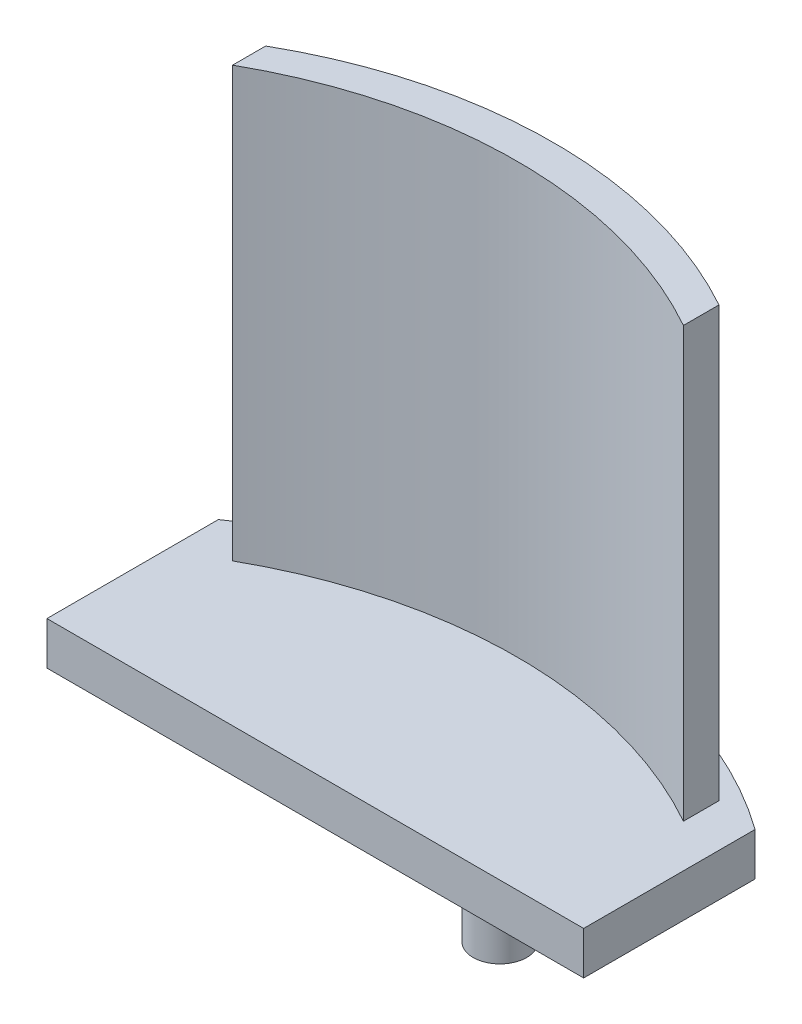
from build123d import *

# Parameters (mm, degrees)
BOSS_EXTRUDE1_DEPTH = 2.54
BOSS_EXTRUDE2_DEPTH = 25.4
SKETCH4_W           = 31.75
SKETCH4_H           = 16.51
CUT_EXTRUDE1_DEPTH  = 2.54
SKETCH5_R           = 1.5875
BOSS_EXTRUDE3_DEPTH = 12.7


with BuildPart() as part:
    # Sketch1 → Boss-Extrude1 (new body)
    with BuildSketch(Plane(origin=(0, 0, 0), x_dir=(1, 0, 0), z_dir=(0, 1, 0))):
        with BuildLine():
            Line((0, 0), (31.75, 0))
            Line((31.75, 0), (31.75, 26.649569904))
            ThreePointArc((31.75, 26.649569904), (15.875, 31.75), (0, 26.649569904))
            Line((0, 26.649569904), (0, 0))
        make_face()
    extrude(amount=BOSS_EXTRUDE1_DEPTH)

    # Sketch2 → Boss-Extrude2 (add)
    with BuildSketch(Plane(origin=(0, 2.54, 0), x_dir=(1, 0, 0), z_dir=(0, 1, 0))):
        with BuildLine():
            Line((2.54, 26.911706478), (2.54, 24.951669261))
            ThreePointArc((2.54, 24.951669261), (15.875, 28.448), (29.21, 24.951669261))
            Line((29.21, 24.951669261), (29.21, 27.054735))
            ThreePointArc((29.21, 27.054735), (15.856249221, 30.479609179), (2.54, 26.911706478))
        make_face()
    extrude(amount=BOSS_EXTRUDE2_DEPTH)

    # Sketch4 → Cut-Extrude1 (cut)
    with BuildSketch(Plane.XZ):
        with Locations((15.875, -8.255)):
            Rectangle(SKETCH4_W, SKETCH4_H)
    extrude(amount=-CUT_EXTRUDE1_DEPTH, mode=Mode.SUBTRACT)

    # Sketch5 → Boss-Extrude3 (add)
    with BuildSketch(Plane.XZ):
        with Locations((14.732, -28.575)):
            Circle(SKETCH5_R)
    extrude(amount=BOSS_EXTRUDE3_DEPTH)


solid = part.part
